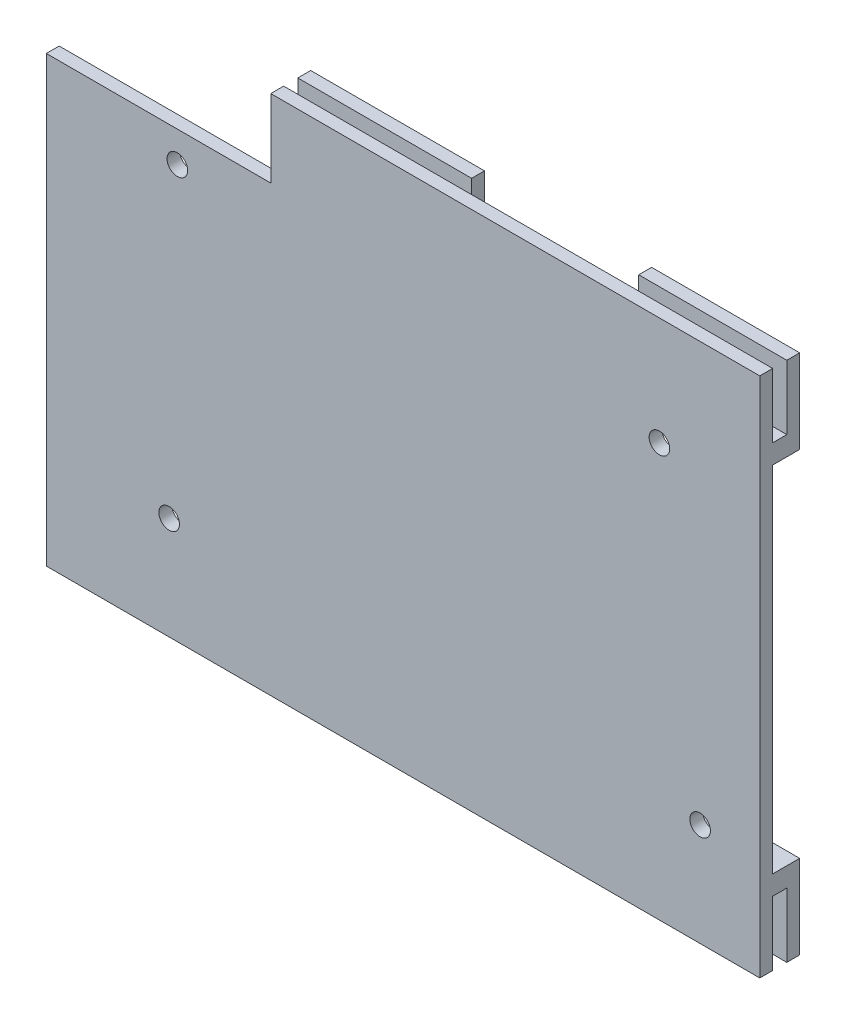
from build123d import *

# Parameters (mm, degrees)
SKETCH1_W           = 110
SKETCH1_H           = 80
BOSS_EXTRUDE1_DEPTH = 2
SKETCH2_R           = 1.6
CUT_EXTRUDE1_DEPTH  = 3
SKETCH3_W           = 34.042558981
SKETCH3_H           = 11.036345557
CUT_EXTRUDE2_DEPTH  = 3
SKETCH4_W           = 2
SKETCH4_H           = 68.963654443
BOSS_EXTRUDE2_DEPTH = 3
SKETCH5_W           = 75.957441019
SKETCH5_H           = 2
BOSS_EXTRUDE3_DEPTH = 1
SKETCH6_W           = 113
SKETCH6_H           = 3
BOSS_EXTRUDE4_DEPTH = 2.2
SKETCH7_W           = 113
SKETCH7_H           = 13
BOSS_EXTRUDE6_DEPTH = 2
SKETCH10_W          = 37.04
SKETCH10_H          = 81
CUT_EXTRUDE5_DEPTH  = 3
SKETCH10_2_W        = 37.04
SKETCH10_2_H        = 81
CUT_EXTRUDE6_DEPTH  = 2.2
SKETCH12_W          = 25.96
SKETCH12_H          = 81
CUT_EXTRUDE7_DEPTH  = 4.2
SKETCH13_W          = 4.352914054
SKETCH13_H          = 137.927308885
CUT_EXTRUDE8_DEPTH  = 3


with BuildPart() as part:
    # Sketch1 → Boss-Extrude1 (new body)
    with BuildSketch(Plane.XY):
        Rectangle(SKETCH1_W, SKETCH1_H)
    extrude(amount=BOSS_EXTRUDE1_DEPTH)

    # Sketch2 → Cut-Extrude1 (cut, through all)
    with BuildSketch(Plane(origin=(0, 0, 0), x_dir=(-1, 0, 0), z_dir=(0, 0, -1))):
        with Locations((35.470952311, 24.181556833)):
            Circle(SKETCH2_R)
        with Locations((-39.411047689, 24.181556833)):
            Circle(SKETCH2_R)
        with Locations((-45.738047689, -24.040443167)):
            Circle(SKETCH2_R)
        with Locations((36.740952311, -24.040443167)):
            Circle(SKETCH2_R)
    extrude(amount=-CUT_EXTRUDE1_DEPTH, mode=Mode.SUBTRACT)

    # Sketch3 → Cut-Extrude2 (cut, through all)
    with BuildSketch(Plane.XY.offset(2)):
        with Locations((-37.97872051, 34.481827221)):
            Rectangle(SKETCH3_W, SKETCH3_H)
    extrude(amount=-CUT_EXTRUDE2_DEPTH, mode=Mode.SUBTRACT)

    # Sketch4 → Boss-Extrude2 (add)
    with BuildSketch(Plane.ZY.offset(55)):
        with Locations((1, -5.518172778)):
            Rectangle(SKETCH4_W, SKETCH4_H)
    extrude(amount=BOSS_EXTRUDE2_DEPTH)

    # Sketch5 → Boss-Extrude3 (add)
    with BuildSketch(Plane(origin=(0, 40, 0), x_dir=(1, 0, 0), z_dir=(0, 1, 0))):
        with Locations((17.02127949, -1)):
            Rectangle(SKETCH5_W, SKETCH5_H)
    extrude(amount=BOSS_EXTRUDE3_DEPTH)

    # Sketch6 → Boss-Extrude4 (add)
    with BuildSketch(Plane(origin=(0, 0, 0), x_dir=(-1, 0, 0), z_dir=(0, 0, -1))):
        with Locations((1.5, 29.5)):
            Rectangle(SKETCH6_W, SKETCH6_H)
        with Locations((1.5, -28.5)):
            Rectangle(SKETCH6_W, SKETCH6_H)
    extrude(amount=BOSS_EXTRUDE4_DEPTH)

    # Sketch7 → Boss-Extrude6 (add)
    with BuildSketch(Plane(origin=(0, 0, -2.2), x_dir=(-1, 0, 0), z_dir=(0, 0, -1))):
        with Locations((1.5, 34.5)):
            Rectangle(SKETCH7_W, SKETCH7_H)
        with Locations((1.5, -33.5)):
            Rectangle(SKETCH7_W, SKETCH7_H)
    extrude(amount=BOSS_EXTRUDE6_DEPTH)

    # Sketch10 → Cut-Extrude5 (cut, through all)
    with BuildSketch(Plane.XY.offset(-2.2)):
        with Locations((-39.48, 0.5)):
            Rectangle(SKETCH10_W, SKETCH10_H)
    extrude(amount=-CUT_EXTRUDE5_DEPTH, mode=Mode.SUBTRACT)

    # Sketch10_2 → Cut-Extrude6 (cut)
    with BuildSketch(Plane.XY.offset(-2.2)):
        with Locations((-39.48, 0.5)):
            Rectangle(SKETCH10_2_W, SKETCH10_2_H)
    extrude(amount=CUT_EXTRUDE6_DEPTH, mode=Mode.SUBTRACT)

    # Sketch12 → Cut-Extrude7 (cut)
    with BuildSketch(Plane(origin=(0, 0, -4.2), x_dir=(-1, 0, 0), z_dir=(0, 0, -1))):
        with Locations((-19.02, 0.5)):
            Rectangle(SKETCH12_W, SKETCH12_H)
    extrude(amount=-CUT_EXTRUDE7_DEPTH, mode=Mode.SUBTRACT)

    # Sketch13 → Cut-Extrude8 (cut, through all)
    with BuildSketch(Plane(origin=(0, 0, 0), x_dir=(-1, 0, 0), z_dir=(0, 0, -1))):
        with Locations((58, 28.963654443)):
            Rectangle(SKETCH13_W, SKETCH13_H)
    extrude(amount=-CUT_EXTRUDE8_DEPTH, mode=Mode.SUBTRACT)


solid = part.part
